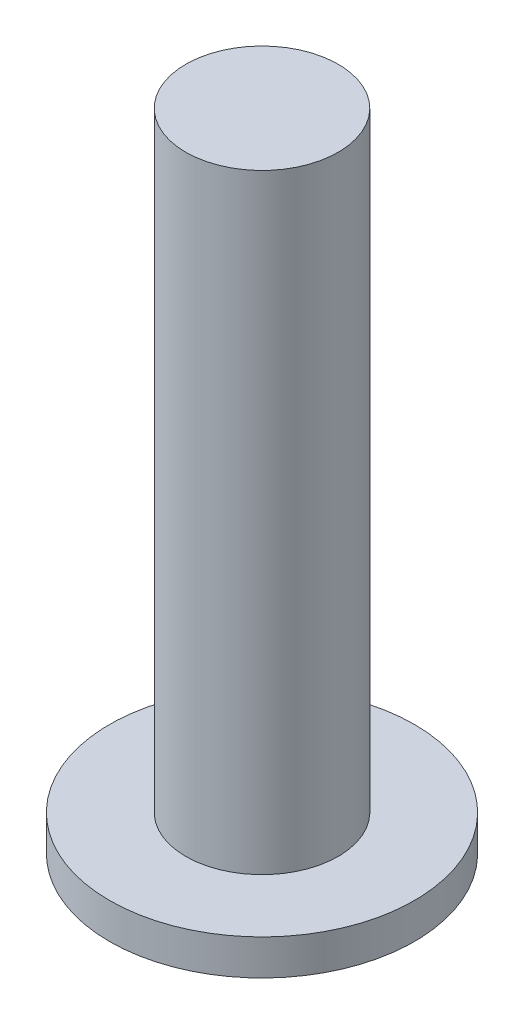
from build123d import *

# Parameters (mm, degrees)
SKETCH1_R           = 1.5
BOSS_EXTRUDE1_DEPTH = 0.35
SKETCH2_R           = 0.75
BOSS_EXTRUDE2_DEPTH = 6


with BuildPart() as part:
    # Sketch1 → Boss-Extrude1 (new body)
    with BuildSketch(Plane(origin=(0, 0, 0), x_dir=(1, 0, 0), z_dir=(0, 1, 0))):
        Circle(SKETCH1_R)
    extrude(amount=BOSS_EXTRUDE1_DEPTH)

    # Sketch2 → Boss-Extrude2 (add)
    with BuildSketch(Plane(origin=(0, 0.35, 0), x_dir=(1, 0, 0), z_dir=(0, 1, 0))):
        Circle(SKETCH2_R)
    extrude(amount=BOSS_EXTRUDE2_DEPTH)


solid = part.part
